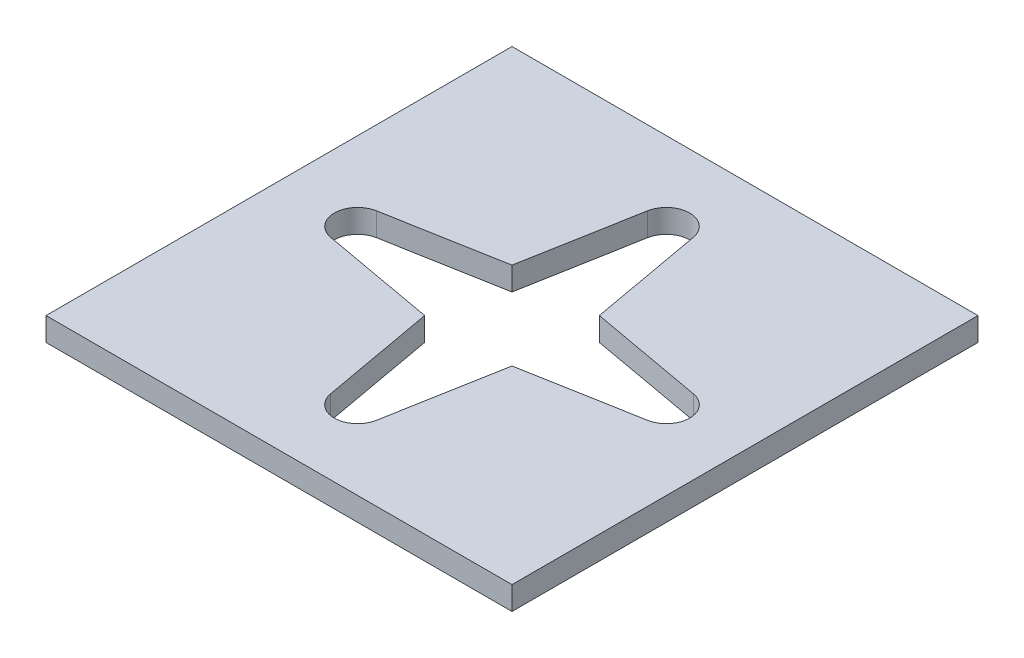
from build123d import *

# Parameters (mm, degrees)
SKETCH1_W           = 50.8
SKETCH1_H           = 50.8
BOSS_EXTRUDE1_DEPTH = 2.54
CUT_EXTRUDE1_DEPTH  = 3.54


with BuildPart() as part:
    # Sketch1 → Boss-Extrude1 (new body)
    with BuildSketch(Plane(origin=(0, 0, 0), x_dir=(1, 0, 0), z_dir=(0, 1, 0))):
        Rectangle(SKETCH1_W, SKETCH1_H)
    extrude(amount=BOSS_EXTRUDE1_DEPTH)

    # Sketch2 → Cut-Extrude1 (cut, through all)
    with BuildSketch(Plane.XZ):
        with BuildLine():
            Line((-4.759535744, 4.759535744), (-2.499599665, 17.278722247))
            ThreePointArc((-2.499599665, 17.278722247), (0, 19.3675), (2.499599665, 17.278722247))
            Line((2.499599665, 17.278722247), (4.759535744, 4.759535744))
            Line((4.759535744, 4.759535744), (17.278722247, 2.499599665))
            ThreePointArc((17.278722247, 2.499599665), (19.3675, 0), (17.278722247, -2.499599665))
            Line((17.278722247, -2.499599665), (4.759535744, -4.759535744))
            Line((4.759535744, -4.759535744), (2.499599665, -17.278722247))
            ThreePointArc((2.499599665, -17.278722247), (0, -19.3675), (-2.499599665, -17.278722247))
            Line((-2.499599665, -17.278722247), (-4.759535744, -4.759535744))
            Line((-4.759535744, -4.759535744), (-17.278722247, -2.499599665))
            ThreePointArc((-17.278722247, -2.499599665), (-19.3675, 0), (-17.278722247, 2.499599665))
            Line((-17.278722247, 2.499599665), (-4.759535744, 4.759535744))
        make_face()
    extrude(amount=-CUT_EXTRUDE1_DEPTH, mode=Mode.SUBTRACT)


solid = part.part
